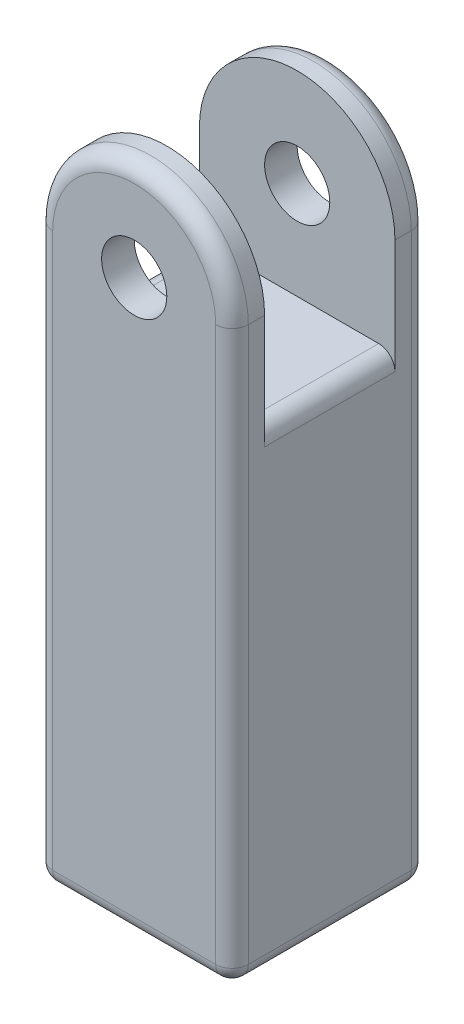
from build123d import *

# Parameters (mm, degrees)
SKETCH_1_W          = 60
SKETCH_1_H          = 60
EXTRUDE_1_DEPTH     = 150
SKETCH_2_R          = 15
CUT_EXTRUDE_1_DEPTH = 30
SKETCH_3_R          = 10
EXTRUDE_2_DEPTH     = 60
SKETCH_4_W          = 40
SKETCH_4_H          = 60
CUT_EXTRUDE_2_DEPTH = 61
FILLET_1_R          = 5


with BuildPart() as part:
    # 草圖1 → 填料-伸長1 (new body)
    with BuildSketch(Plane(origin=(0, 0, 0), x_dir=(1, 0, 0), z_dir=(0, 1, 0))):
        Rectangle(SKETCH_1_W, SKETCH_1_H)
    extrude(amount=EXTRUDE_1_DEPTH)

    # 草圖2 → 除料-伸長1 (cut)
    with BuildSketch(Plane.XZ):
        Circle(SKETCH_2_R)
    extrude(amount=-CUT_EXTRUDE_1_DEPTH, mode=Mode.SUBTRACT)

    # 草圖3 → 填料-伸長2 (add)
    with BuildSketch(Plane.XY.offset(30)):
        with BuildLine():
            Line((-30, 150), (-30, 175))
            ThreePointArc((-30, 175), (0, 205), (30, 175))
            Line((30, 175), (30, 150))
            Line((30, 150), (-30, 150))
        make_face()
        with Locations((0, 175)):
            Circle(SKETCH_3_R, mode=Mode.SUBTRACT)
    extrude(amount=-EXTRUDE_2_DEPTH)

    # 草圖4 → 除料-伸長2 (cut, through all)
    with BuildSketch(Plane.ZY.offset(30)):
        with Locations((0, 175)):
            Rectangle(SKETCH_4_W, SKETCH_4_H)
    extrude(amount=-CUT_EXTRUDE_2_DEPTH, mode=Mode.SUBTRACT)

    # 圓角1
    fillet_1_edges = [part.edges().sort_by_distance(p)[0] for p in [
        (0, 205, 30),
        (0, 205, -30),
        (-30, 145, 0),
        (30, 145, 0),
        (0, 0, 30),
        (-30, 0, 0),
        (0, 0, -30),
        (30, 0, 0),
        (30, 87.5, 30),
        (-30, 87.5, 30),
        (-30, 87.5, -30),
        (30, 87.5, -30),
    ]]
    fillet(fillet_1_edges, radius=FILLET_1_R)


solid = part.part
